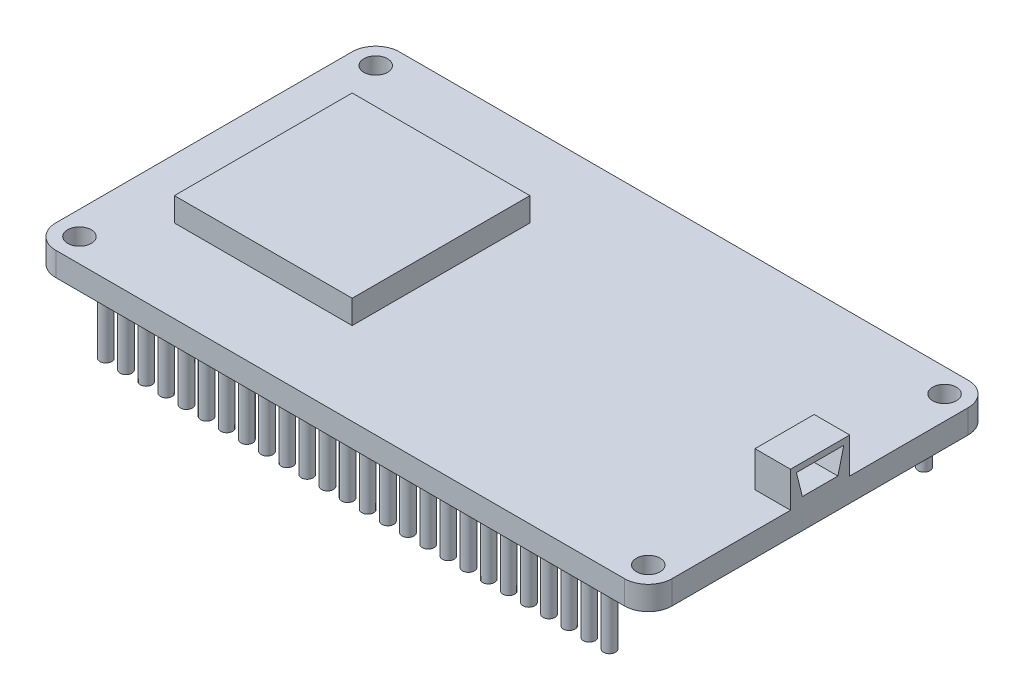
from build123d import *

# Parameters (mm, degrees)
ESBO_O1_R                = 1
RESSALTO_EXTRUS_O1_DEPTH = 2
ESBO_O2_R                = 0.5
RESSALTO_EXTRUS_O2_DEPTH = 5
ESBO_O3_W                = 3
ESBO_O3_H                = 5
RESSALTO_EXTRUS_O3_DEPTH = 3
CORTE_EXTRUS_O1_DEPTH    = 2
ESBO_O5_W                = 15
ESBO_O5_H                = 15
RESSALTO_EXTRUS_O4_DEPTH = 2


with BuildPart() as part:
    # Esboço1 → Ressalto-extrusão1 (new body)
    with BuildSketch(Plane(origin=(0, 0, 0), x_dir=(1, 0, 0), z_dir=(0, 1, 0))):
        with BuildLine():
            Line((-25.276485788, 12.630490956), (22.723514212, 12.630490956))
            ThreePointArc((22.723514212, 12.630490956), (24.137727774, 12.044704518), (24.723514212, 10.630490956))
            Line((24.723514212, 10.630490956), (24.723514212, -14.369509044))
            ThreePointArc((24.723514212, -14.369509044), (24.137727774, -15.783722606), (22.723514212, -16.369509044))
            Line((22.723514212, -16.369509044), (-25.276485788, -16.369509044))
            ThreePointArc((-25.276485788, -16.369509044), (-26.69069935, -15.783722606), (-27.276485788, -14.369509044))
            Line((-27.276485788, -14.369509044), (-27.276485788, 10.630490956))
            ThreePointArc((-27.276485788, 10.630490956), (-26.69069935, 12.044704518), (-25.276485788, 12.630490956))
        make_face()
        with Locations((-25.276485788, 10.630490956)):
            Circle(ESBO_O1_R, mode=Mode.SUBTRACT)
        with Locations((-25.276485788, -14.369509044)):
            Circle(ESBO_O1_R, mode=Mode.SUBTRACT)
        with Locations((22.723514212, 10.630490956)):
            Circle(ESBO_O1_R, mode=Mode.SUBTRACT)
        with Locations((22.723514212, -14.369509044)):
            Circle(ESBO_O1_R, mode=Mode.SUBTRACT)
    extrude(amount=RESSALTO_EXTRUS_O1_DEPTH)

    # Esboço2 → Ressalto-extrusão2 (add)
    with BuildSketch(Plane.XZ):
        with Locations((-22.276485788, 15.14160434)):
            Circle(ESBO_O2_R)
        with Locations((-20.576485788, 15.14160434)):
            Circle(ESBO_O2_R)
        with Locations((-18.876485788, 15.14160434)):
            Circle(ESBO_O2_R)
        with Locations((-17.176485788, 15.14160434)):
            Circle(ESBO_O2_R)
        with Locations((-15.476485788, 15.14160434)):
            Circle(ESBO_O2_R)
        with Locations((-13.776485788, 15.14160434)):
            Circle(ESBO_O2_R)
        with Locations((-12.076485788, 15.14160434)):
            Circle(ESBO_O2_R)
        with Locations((-10.376485788, 15.14160434)):
            Circle(ESBO_O2_R)
        with Locations((-8.676485788, 15.14160434)):
            Circle(ESBO_O2_R)
        with Locations((-6.976485788, 15.14160434)):
            Circle(ESBO_O2_R)
        with Locations((-5.276485788, 15.14160434)):
            Circle(ESBO_O2_R)
        with Locations((-3.576485788, 15.14160434)):
            Circle(ESBO_O2_R)
        with Locations((-1.876485788, 15.14160434)):
            Circle(ESBO_O2_R)
        with Locations((-0.176485788, 15.14160434)):
            Circle(ESBO_O2_R)
        with Locations((1.523514212, 15.14160434)):
            Circle(ESBO_O2_R)
        with Locations((3.223514212, 15.14160434)):
            Circle(ESBO_O2_R)
        with Locations((4.923514212, 15.14160434)):
            Circle(ESBO_O2_R)
        with Locations((6.623514212, 15.14160434)):
            Circle(ESBO_O2_R)
        with Locations((8.323514212, 15.14160434)):
            Circle(ESBO_O2_R)
        with Locations((10.023514212, 15.14160434)):
            Circle(ESBO_O2_R)
        with Locations((11.723514212, 15.14160434)):
            Circle(ESBO_O2_R)
        with Locations((13.423514212, 15.14160434)):
            Circle(ESBO_O2_R)
        with Locations((15.123514212, 15.14160434)):
            Circle(ESBO_O2_R)
        with Locations((16.823514212, 15.14160434)):
            Circle(ESBO_O2_R)
        with Locations((18.523514212, 15.14160434)):
            Circle(ESBO_O2_R)
        with Locations((20.223514212, 15.14160434)):
            Circle(ESBO_O2_R)
        with Locations((-22.276485788, -11.402586252)):
            Circle(ESBO_O2_R)
        with Locations((-20.576485788, -11.402586252)):
            Circle(ESBO_O2_R)
        with Locations((-18.876485788, -11.402586252)):
            Circle(ESBO_O2_R)
        with Locations((-17.176485788, -11.402586252)):
            Circle(ESBO_O2_R)
        with Locations((-15.476485788, -11.402586252)):
            Circle(ESBO_O2_R)
        with Locations((-13.776485788, -11.402586252)):
            Circle(ESBO_O2_R)
        with Locations((-12.076485788, -11.402586252)):
            Circle(ESBO_O2_R)
        with Locations((-10.376485788, -11.402586252)):
            Circle(ESBO_O2_R)
        with Locations((-8.676485788, -11.402586252)):
            Circle(ESBO_O2_R)
        with Locations((-6.976485788, -11.402586252)):
            Circle(ESBO_O2_R)
        with Locations((-5.276485788, -11.402586252)):
            Circle(ESBO_O2_R)
        with Locations((-3.576485788, -11.402586252)):
            Circle(ESBO_O2_R)
        with Locations((-1.876485788, -11.402586252)):
            Circle(ESBO_O2_R)
        with Locations((-0.176485788, -11.402586252)):
            Circle(ESBO_O2_R)
        with Locations((1.523514212, -11.402586252)):
            Circle(ESBO_O2_R)
        with Locations((3.223514212, -11.402586252)):
            Circle(ESBO_O2_R)
        with Locations((4.923514212, -11.402586252)):
            Circle(ESBO_O2_R)
        with Locations((6.623514212, -11.402586252)):
            Circle(ESBO_O2_R)
        with Locations((8.323514212, -11.402586252)):
            Circle(ESBO_O2_R)
        with Locations((10.023514212, -11.402586252)):
            Circle(ESBO_O2_R)
        with Locations((11.723514212, -11.402586252)):
            Circle(ESBO_O2_R)
        with Locations((13.423514212, -11.402586252)):
            Circle(ESBO_O2_R)
        with Locations((15.123514212, -11.402586252)):
            Circle(ESBO_O2_R)
        with Locations((16.823514212, -11.402586252)):
            Circle(ESBO_O2_R)
        with Locations((18.523514212, -11.402586252)):
            Circle(ESBO_O2_R)
        with Locations((20.223514212, -11.402586252)):
            Circle(ESBO_O2_R)
    extrude(amount=RESSALTO_EXTRUS_O2_DEPTH)

    # Esboço3 → Ressalto-extrusão3 (add)
    with BuildSketch(Plane(origin=(0, 2, 0), x_dir=(1, 0, 0), z_dir=(0, 1, 0))):
        with Locations((23.223514212, -1.869509044)):
            Rectangle(ESBO_O3_W, ESBO_O3_H)
    extrude(amount=RESSALTO_EXTRUS_O3_DEPTH)

    # Esboço4 → Corte-extrusão1 (cut)
    with BuildSketch(Plane(origin=(24.723514212, 0, 0), x_dir=(0, 0, -1), z_dir=(1, 0, 0))):
        Polygon((0.130490956, 4.5), (-0.369509044, 2.5), (-3.369509044, 2.5), (-3.869509044, 4.5), align=None)
    extrude(amount=-CORTE_EXTRUS_O1_DEPTH, mode=Mode.SUBTRACT)

    # Esboço5 → Ressalto-extrusão4 (add)
    with BuildSketch(Plane(origin=(0, 2, 0), x_dir=(1, 0, 0), z_dir=(0, 1, 0))):
        with Locations((-14.764317849, -1.869509044)):
            Rectangle(ESBO_O5_W, ESBO_O5_H)
    extrude(amount=RESSALTO_EXTRUS_O4_DEPTH)


solid = part.part
